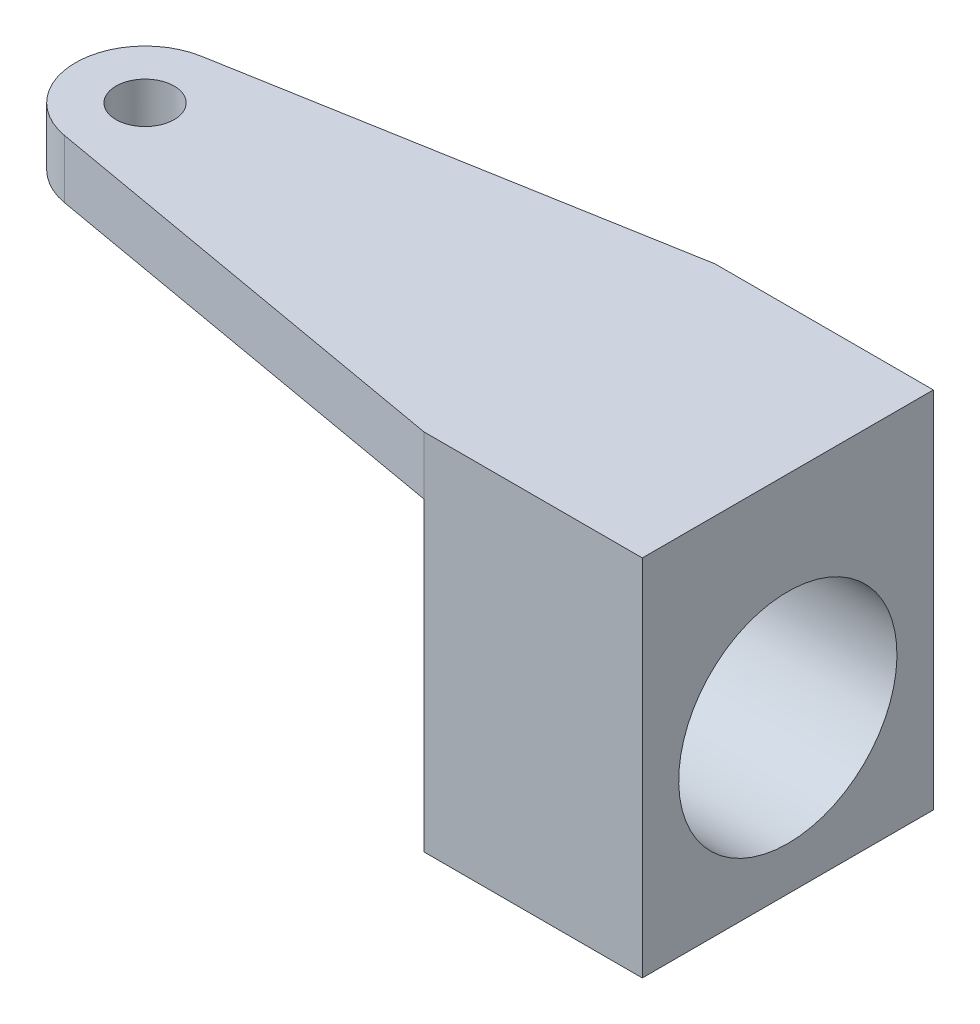
from build123d import *

# Parameters (mm, degrees)
SKETCH1_R           = 10
BOSS_EXTRUDE1_DEPTH = 125
CUT_EXTRUDE1_DEPTH  = 105
SKETCH5_R           = 37.5
CUT_EXTRUDE2_DEPTH  = 76


with BuildPart() as part:
    # Sketch1 → Boss-Extrude1 (new body)
    with BuildSketch(Plane(origin=(0, 0, 0), x_dir=(-1, 0, 0), z_dir=(0, -1, 0))):
        with BuildLine():
            Line((-220.847331583, 50), (-145.847331583, 50))
            Line((-145.847331583, 50), (4.152668417, 23.550952894))
            ThreePointArc((4.152668417, 23.550952894), (23.914264304, 0), (4.152668417, -23.550952894))
            Line((4.152668417, -23.550952894), (-145.847331583, -50))
            Line((-145.847331583, -50), (-220.847331583, -50))
            Line((-220.847331583, -50), (-220.847331583, 50))
        make_face()
        Circle(SKETCH1_R, mode=Mode.SUBTRACT)
    extrude(amount=BOSS_EXTRUDE1_DEPTH)

    # Sketch2 → Cut-Extrude1 (cut)
    with BuildSketch(Plane(origin=(0, -125, 0), x_dir=(-1, 0, 0), z_dir=(0, -1, 0))):
        with BuildLine():
            Line((-145.847331583, 50), (-145.847331583, -50))
            Line((-145.847331583, -50), (4.152668417, -23.550952894))
            ThreePointArc((4.152668417, -23.550952894), (23.914264304, 0), (4.152668417, 23.550952894))
            Line((4.152668417, 23.550952894), (-145.847331583, 50))
        make_face()
    extrude(amount=-CUT_EXTRUDE1_DEPTH, mode=Mode.SUBTRACT)

    # Sketch5 → Cut-Extrude2 (cut, through all)
    with BuildSketch(Plane(origin=(145.847331583, 0, 0), x_dir=(0, 0, -1), z_dir=(-1, 0, 0))):
        with Locations((0, 72.5)):
            Circle(SKETCH5_R)
    extrude(amount=-CUT_EXTRUDE2_DEPTH, mode=Mode.SUBTRACT)


solid = part.part
